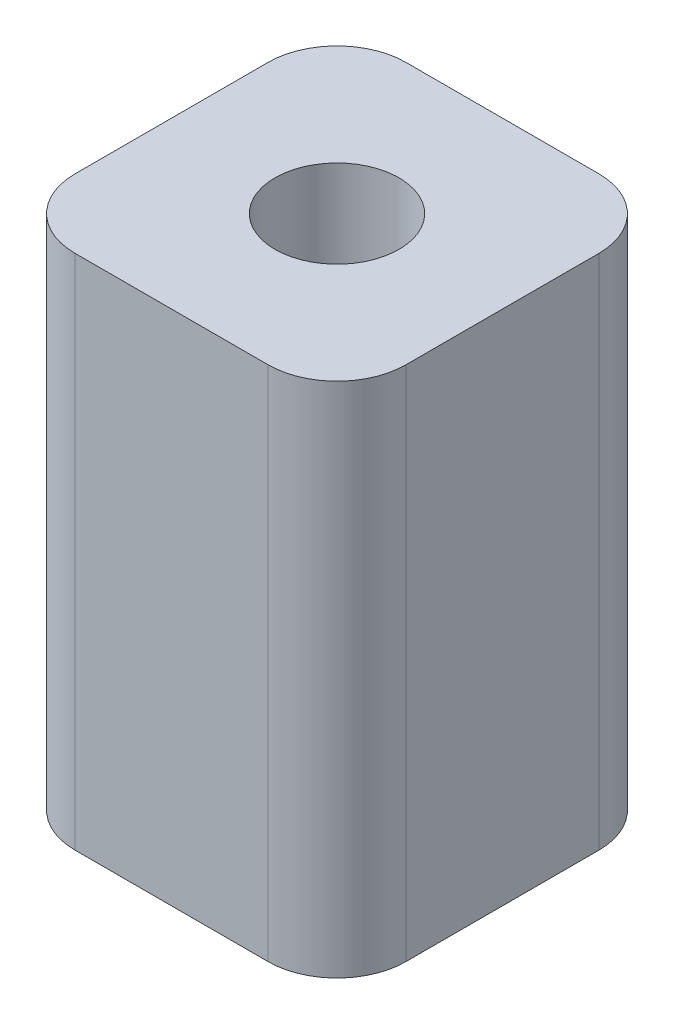
from build123d import *

# Parameters (mm, degrees)
SKETCH1_W           = 9.6
SKETCH1_H           = 9.6
SKETCH1_R           = 1.8
BOSS_EXTRUDE1_DEPTH = 7.5
FILLET1_R           = 2


with BuildPart() as part:
    # Sketch1 → Boss-Extrude1 (new body, symmetric)
    with BuildSketch(Plane(origin=(0, 0, 0), x_dir=(1, 0, 0), z_dir=(0, 1, 0))):
        Rectangle(SKETCH1_W, SKETCH1_H)
        Circle(SKETCH1_R, mode=Mode.SUBTRACT)
    extrude(amount=BOSS_EXTRUDE1_DEPTH, both=True)

    # Fillet1
    fillet1_edges = [part.edges().sort_by_distance(p)[0] for p in [
        (-4.8, 0, -4.8),
        (4.8, 0, -4.8),
        (4.8, 0, 4.8),
        (-4.8, 0, 4.8),
    ]]
    fillet(fillet1_edges, radius=FILLET1_R)


solid = part.part
